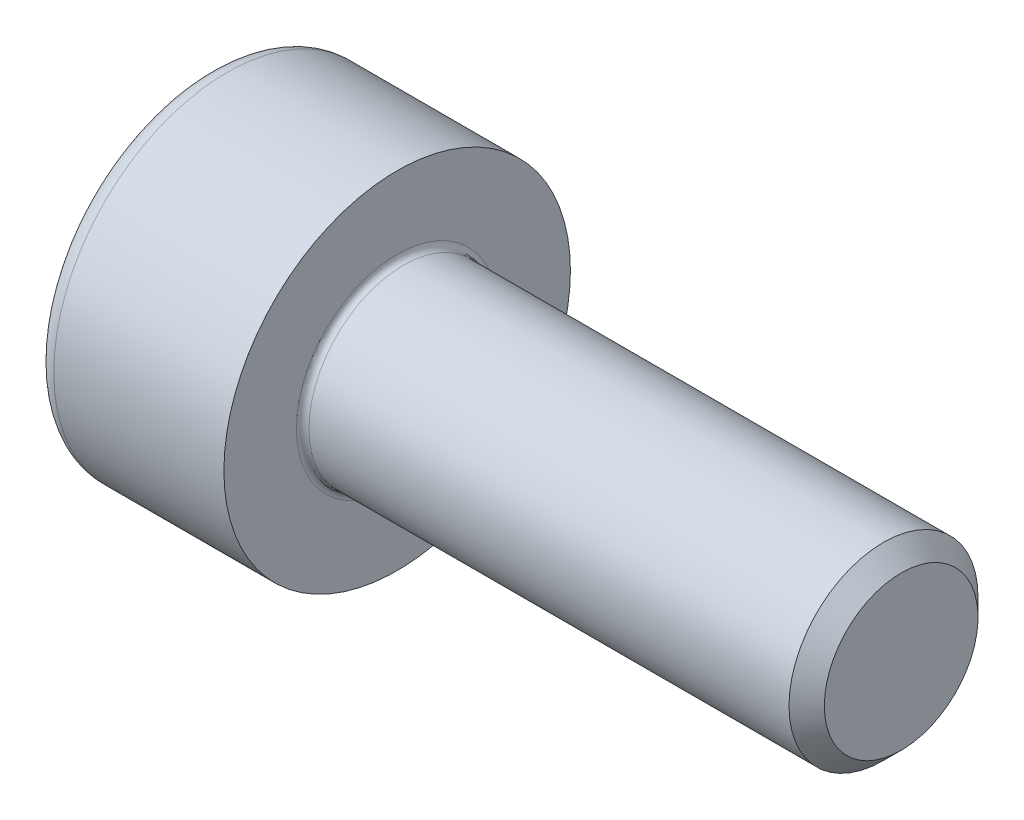
from build123d import *

# Parameters (mm, degrees)
FILLET1_R   = 0.1
FILLET2_R   = 0.3
HEX_2_DEPTH = 1.3


with BuildPart() as part:
    # BodySke → Base-Revolve (revolve)
    with BuildSketch(Plane.XY):
        Polygon((0, 0), (0, 2.75), (3, 2.75), (3, 1.5), (10.7195, 1.5), (11, 1.2195), (11, 0), align=None)
    revolve(axis=Axis((-31.75, 0, 0), (1, 0, 0)))

    # Fillet1
    fillet1_edges = [part.edges().sort_by_distance(p)[0] for p in [
        (3, -1.5, 0),
    ]]
    fillet(fillet1_edges, radius=FILLET1_R)

    # Fillet2
    fillet2_edges = [part.edges().sort_by_distance(p)[0] for p in [
        (0, -2.75, 0),
    ]]
    fillet(fillet2_edges, radius=FILLET2_R)

    # Sketch2 → Hex-PreBroach (revolve, cut)
    with BuildSketch(Plane.XY):
        Polygon((0, 1.26), (1.3, 1.26), (2.027461339, 0), (0, 0), align=None)
    revolve(axis=Axis((0, 0, 0), (1, 0, 0)), mode=Mode.SUBTRACT)

    # Sketch3 → Hex 2 (cut)
    with BuildSketch(Plane(origin=(0, 0, 0), x_dir=(0, 0.5, 0.866025404), z_dir=(-1, 0, 0))):
        Polygon((0.727461339, 1.26), (-0.727461339, 1.26), (-1.454922678, 0), (-0.727461339, -1.26), (0.727461339, -1.26), (1.454922678, 0), align=None)
    extrude(amount=-HEX_2_DEPTH, mode=Mode.SUBTRACT)


solid = part.part
